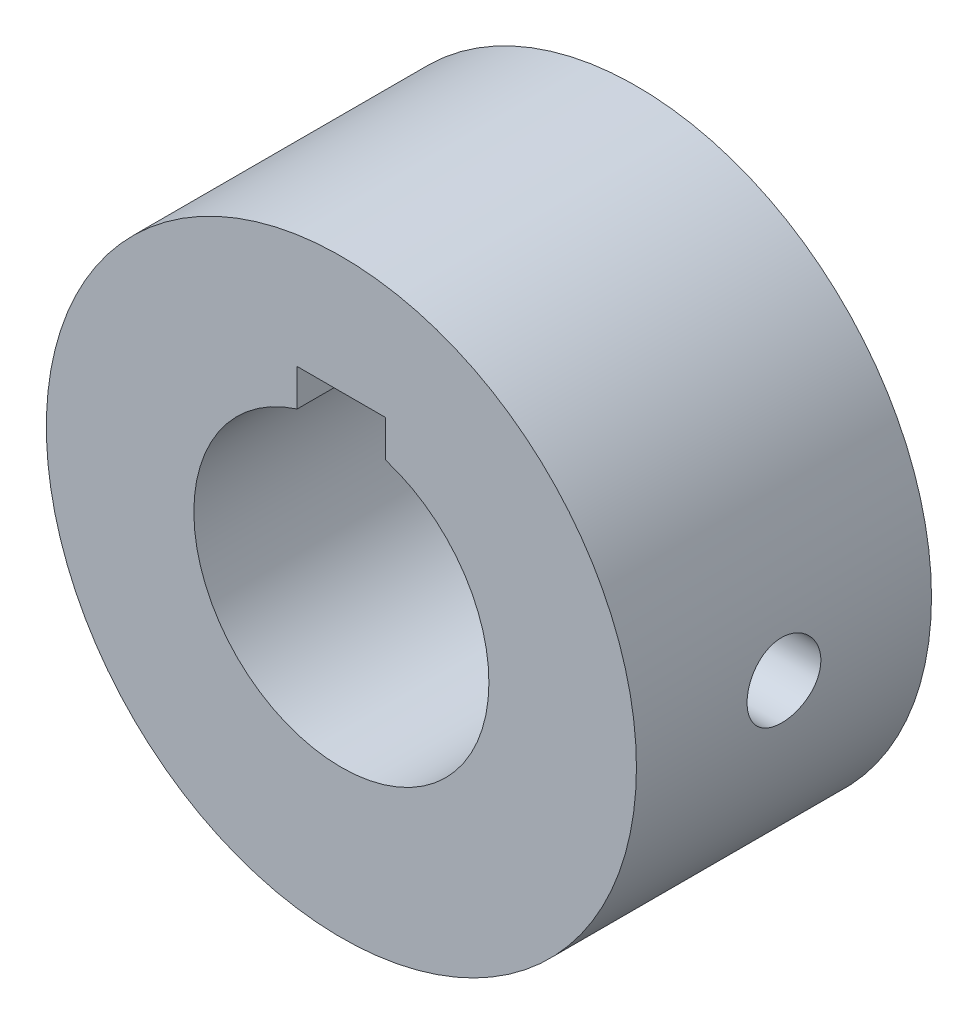
from build123d import *

# Parameters (mm, degrees)
ESQUISSE1_R             = 20
BOSS_EXTRU_1_DEPTH      = 20
TROU_TARAUD_M61_D       = 5
TROU_TARAUD_M61_DEPTH   = 17
TROU_TARAUD_M61_TIP     = 1.502151548
ENL_V_MAT_EXTRU_1_DEPTH = 25


with BuildPart() as part:
    # Esquisse1 → Boss.-Extru.1 (new body)
    with BuildSketch(Plane.XY):
        Circle(ESQUISSE1_R)
    extrude(amount=BOSS_EXTRU_1_DEPTH)

    # Trou taraudé M61
    with Locations(Plane(origin=(19.999953956, 0.042915747, 10), x_dir=(-0.002145787, 0.999997698, 0), z_dir=(0.999997698, 0.002145787, 0))):
        with Locations((0, 0)):
            Hole(TROU_TARAUD_M61_D / 2, depth=TROU_TARAUD_M61_DEPTH)
            with Locations((0, 0, -(TROU_TARAUD_M61_DEPTH + TROU_TARAUD_M61_TIP / 2))):  # 118° drill point
                Cone(0, TROU_TARAUD_M61_D / 2, TROU_TARAUD_M61_TIP, mode=Mode.SUBTRACT)

    # Esquisse11 → Enlèv. mat.-Extru.1 (cut)
    with BuildSketch(Plane.XY.offset(20)):
        with BuildLine():
            Line((3, 9.539392014), (3, 12.039392014))
            Line((3, 12.039392014), (-3, 12.039392014))
            Line((-3, 12.039392014), (-3, 9.539392014))
            ThreePointArc((-3, 9.539392014), (0, -10), (3, 9.539392014))
        make_face()
    extrude(amount=-ENL_V_MAT_EXTRU_1_DEPTH, mode=Mode.SUBTRACT)


solid = part.part
